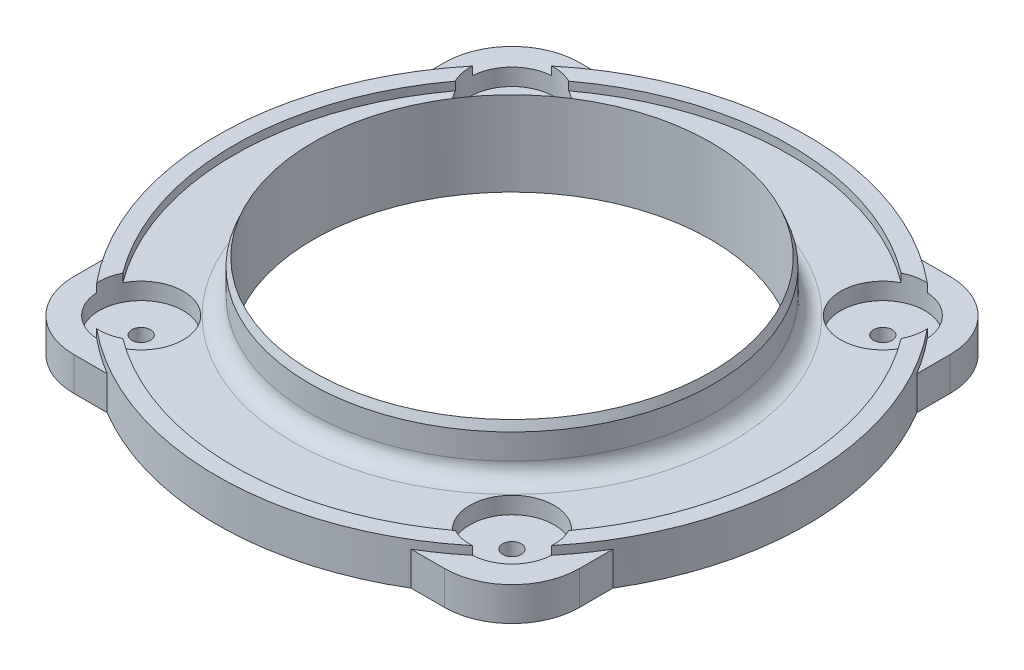
from build123d import *

# Parameters (mm, degrees)
SKETCH1_W               = 95.25
SKETCH1_H               = 95.25
SKETCH1_R               = 37.465
BOSS_EXTRUDE1_DEPTH     = 6.35
SKETCH2_R               = 1.75
CUT_EXTRUDE1_DEPTH      = 68.650600515
CIRPATTERN1_COUNT       = 4
FILLET1_R               = 12.7
FILLET2_R               = 3.175
SKETCH5_R               = 55.5625
SKETCH5_R_2             = 44.45
SKETCH5_R_3             = 1.75
BOSS_EXTRUDE2_DEPTH     = 6.35
BOSS_EXTRUDE4_START     = 1.5875
SKETCH8_R               = 55.5625
SKETCH8_R_2             = 52.3875
BOSS_EXTRUDE4_DEPTH     = 1.5875
CUT_EXTRUDE3_DEPTH      = 80.152437976
CUT_EXTRUDE3_DEPTH_BACK = 3.175
SKETCH10_R              = 7.9375


with BuildPart() as part:
    # Sketch1 → Boss-Extrude1 (new body)
    with BuildSketch(Plane(origin=(0, 0, 0), x_dir=(1, 0, 0), z_dir=(0, 1, 0))):
        Rectangle(SKETCH1_W, SKETCH1_H)
        with Locations(Location((0, 0, 0), (0, 0, 270))):
            Circle(SKETCH1_R, mode=Mode.SUBTRACT)
    extrude(amount=BOSS_EXTRUDE1_DEPTH)

    # Sketch2 → Cut-Extrude1 (cut, through all)
    with BuildSketch(Plane(origin=(0, 6.35, 0), x_dir=(1, 0, 0), z_dir=(0, 1, 0))):
        with Locations(Location((-34.925, 34.925, 0), (0, 0, 270))):
            Circle(SKETCH2_R)
    cut_extrude1 = extrude(amount=-CUT_EXTRUDE1_DEPTH, mode=Mode.SUBTRACT)

    # CirPattern1: Cut-Extrude1 ×4 about axis
    cirpattern1_axis = Axis((0, 0, 0), (0, 1, 0))
    for i in range(1, CIRPATTERN1_COUNT):
        add(cut_extrude1.rotate(cirpattern1_axis, i * 360 / CIRPATTERN1_COUNT), mode=Mode.SUBTRACT)

    # Fillet1
    fillet1_edges = [part.edges().sort_by_distance(p)[0] for p in [
        (-47.625, 3.175, -47.625),
        (47.625, 3.175, -47.625),
        (47.625, 3.175, 47.625),
        (-47.625, 3.175, 47.625),
    ]]
    fillet(fillet1_edges, radius=FILLET1_R)

    # Sketch4 → Revolve1 (revolve)
    with BuildSketch(Plane.XY, mode=Mode.PRIVATE) as revolve1_sk:
        Polygon((37.465, 12.7), (37.465, 6.35), (38.1, 6.35), (38.1, 10.3505), (38.1, 14.2875), (37.465, 15.875), align=None)
    revolve(revolve1_sk.sketch.rotate(Axis((0, 0, 0), (0, 1, 0)), 90), axis=Axis((0, 0, 0), (0, 1, 0)))

    # Fillet2
    fillet2_edges = [part.edges().sort_by_distance(p)[0] for p in [
        (0, 6.35, 38.1),
    ]]
    fillet(fillet2_edges, radius=FILLET2_R)

    # Sketch5 → Boss-Extrude2 (add, through all)
    with BuildSketch(Plane(origin=(0, 6.35, 0), x_dir=(1, 0, 0), z_dir=(0, 1, 0))):
        Circle(SKETCH5_R)
        Circle(SKETCH5_R_2, mode=Mode.SUBTRACT)
        with Locations(Location((-34.925, 34.925, 0), (0, 0, 270))):
            Circle(SKETCH5_R_3, mode=Mode.SUBTRACT)
        with Locations((-34.925, -34.925)):
            Circle(SKETCH5_R_3, mode=Mode.SUBTRACT)
        with Locations(Location((34.925, -34.925, 0), (0, 0, 90))):
            Circle(SKETCH5_R_3, mode=Mode.SUBTRACT)
        with Locations(Location((34.925, 34.925, 0), (0, 0, 180))):
            Circle(SKETCH5_R_3, mode=Mode.SUBTRACT)
    extrude(amount=-BOSS_EXTRUDE2_DEPTH)

    # Sketch8 → Boss-Extrude4 (add)
    with BuildSketch(Plane(origin=(0, 6.35, 0), x_dir=(1, 0, 0), z_dir=(0, 1, 0)).offset(BOSS_EXTRUDE4_START)):
        with Locations(Location((0, 0, 0), (0, 0, 270))):
            Circle(SKETCH8_R)
        with Locations(Location((0, 0, 0), (0, 0, 270))):
            Circle(SKETCH8_R_2, mode=Mode.SUBTRACT)
    extrude(amount=-BOSS_EXTRUDE4_DEPTH)

    # Sketch10 → Cut-Extrude3 (cut, two sides: drawn at the far end of the back side and taken through both)
    with BuildSketch(Plane(origin=(0, 6.35, 0), x_dir=(1, 0, 0), z_dir=(0, 1, 0)).offset(-CUT_EXTRUDE3_DEPTH_BACK)):
        with Locations(Location((-34.925, 34.925, 0), (0, 0, 270))):
            Circle(SKETCH10_R)
        with Locations(Location((34.925, 34.925, 0), (0, 0, 270))):
            Circle(SKETCH10_R)
        with Locations(Location((34.925, -34.925, 0), (0, 0, 270))):
            Circle(SKETCH10_R)
        with Locations(Location((-34.925, -34.925, 0), (0, 0, 270))):
            Circle(SKETCH10_R)
    extrude(amount=CUT_EXTRUDE3_DEPTH + CUT_EXTRUDE3_DEPTH_BACK, mode=Mode.SUBTRACT)


solid = part.part
